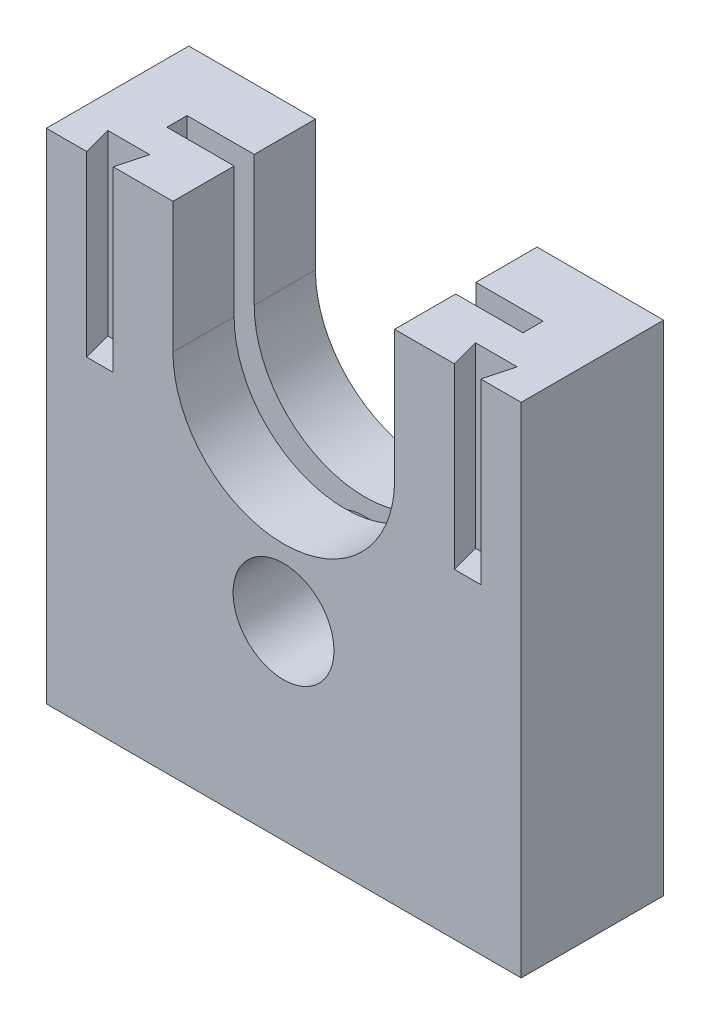
from build123d import *

# Parameters (mm, degrees)
SKETCH2_W           = 36
SKETCH2_H           = 42
BOSS_EXTRUDE1_DEPTH = 12
CUT_EXTRUDE1_DEPTH  = 15
CUT_EXTRUDE2_DEPTH  = 12
SKETCH5_W           = 30
SKETCH5_H           = 1.695405108
CUT_EXTRUDE3_DEPTH  = 25
SKETCH6_R           = 4.25
CUT_EXTRUDE4_DEPTH  = 7.1
SKETCH7_W           = 2
SKETCH7_H           = 12
BOSS_EXTRUDE2_DEPTH = 42


with BuildPart() as part:
    # Sketch2 → Boss-Extrude1 (new body)
    with BuildSketch(Plane.XY):
        with Locations((-1.487179487, 11.461538462)):
            Rectangle(SKETCH2_W, SKETCH2_H)
    extrude(amount=BOSS_EXTRUDE1_DEPTH)

    # Sketch3 → Cut-Extrude1 (cut)
    with BuildSketch(Plane(origin=(0, 32.461538462, 0), x_dir=(1, 0, 0), z_dir=(0, 1, 0))):
        Polygon((-18.087179487, -12), (-18.736956279, -9.575), (-15.212402696, -9.575), (-15.862179487, -12), align=None)
        Polygon((15.112820513, -12), (15.762597304, -9.575), (12.238043721, -9.575), (12.887820513, -12), align=None)
    extrude(amount=-CUT_EXTRUDE1_DEPTH, mode=Mode.SUBTRACT)

    # Sketch4 → Cut-Extrude2 (cut)
    with BuildSketch(Plane.XY.offset(12)):
        with BuildLine():
            Line((-10.823469947, 32.461538462), (7.849110972, 32.461538462))
            Line((7.849110972, 32.461538462), (7.849110972, 21.461538462))
            ThreePointArc((7.849110972, 21.461538462), (-1.487179487, 12.125248002), (-10.823469947, 21.461538462))
            Line((-10.823469947, 21.461538462), (-10.823469947, 32.461538462))
        make_face()
    extrude(amount=-CUT_EXTRUDE2_DEPTH, mode=Mode.SUBTRACT)

    # Sketch5 → Cut-Extrude3 (cut)
    with BuildSketch(Plane(origin=(0, 32.461538462, 0), x_dir=(1, 0, 0), z_dir=(0, 1, 0))):
        with Locations((-1.487179487, -6)):
            Rectangle(SKETCH5_W, SKETCH5_H)
    extrude(amount=-CUT_EXTRUDE3_DEPTH, mode=Mode.SUBTRACT)

    # Sketch6 → Cut-Extrude4 (cut)
    with BuildSketch(Plane.XY.offset(12)):
        with Locations((-1.509360089, 6.461538462)):
            Circle(SKETCH6_R)
    extrude(amount=-CUT_EXTRUDE4_DEPTH, mode=Mode.SUBTRACT)

    # Sketch7 → Boss-Extrude2 (add)
    with BuildSketch(Plane(origin=(0, 32.461538462, 0), x_dir=(1, 0, 0), z_dir=(0, 1, 0))):
        with Locations((-20.487179487, -6)):
            Rectangle(SKETCH7_W, SKETCH7_H)
        with Locations((17.512820513, -6)):
            Rectangle(SKETCH7_W, SKETCH7_H)
    extrude(amount=-BOSS_EXTRUDE2_DEPTH)


solid = part.part
